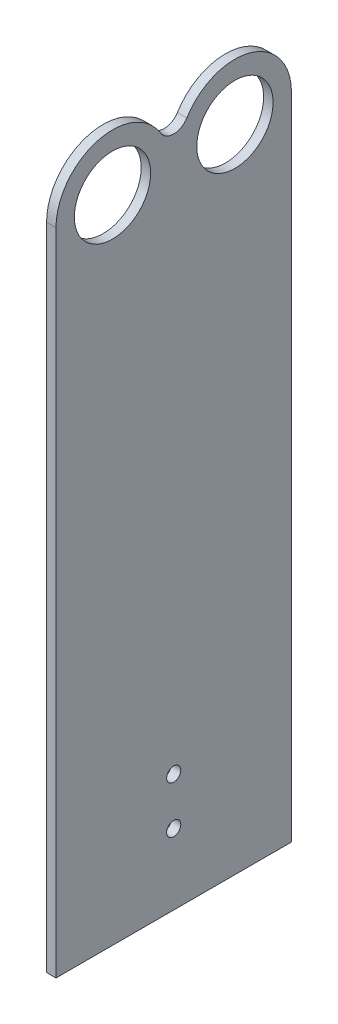
from build123d import *

# Parameters (mm, degrees)
SKETCH1_W               = 2
SKETCH1_H               = 150
BOSS_EXTRUDE1_DEPTH     = 50
SKETCH3_R               = 8.1
CUT_EXTRUDE2_DEPTH      = 50
SKETCH4_R               = 1.5
CUT_EXTRUDE3_DEPTH      = 1
CUT_EXTRUDE3_DEPTH_BACK = 3


with BuildPart() as part:
    # Sketch1 → Boss-Extrude1 (new body)
    with BuildSketch(Plane.XY):
        with Locations((1, -40)):
            Rectangle(SKETCH1_W, SKETCH1_H)
    extrude(amount=BOSS_EXTRUDE1_DEPTH)

    # Sketch3 → Cut-Extrude2 (cut)
    with BuildSketch(Plane(origin=(2, 0, 0), x_dir=(0, 0, -1), z_dir=(1, 0, 0))):
        with Locations((-12, 23)):
            Circle(SKETCH3_R)
        with Locations((-38, 23)):
            Circle(SKETCH3_R)
        with BuildLine():
            ThreePointArc((-50, 23), (-46.485281374, 31.485281374), (-38, 35))
            Line((-38, 35), (-50, 35))
            Line((-50, 35), (-50, 23))
        make_face()
        with BuildLine():
            ThreePointArc((-22.2198998, 29.289169108), (-17.8536301, 33.475448184), (-12, 35))
            Line((-12, 35), (-38, 35))
            ThreePointArc((-38, 35), (-32.1463699, 33.475448184), (-27.7801002, 29.289169108))
            ThreePointArc((-27.7801002, 29.289169108), (-25, 27.735662478), (-22.2198998, 29.289169108))
        make_face()
        with BuildLine():
            Line((0, 35), (-12, 35))
            ThreePointArc((-12, 35), (-3.514718626, 31.485281374), (0, 23))
            Line((0, 23), (0, 35))
        make_face()
    extrude(amount=-CUT_EXTRUDE2_DEPTH, mode=Mode.SUBTRACT)

    # Sketch4 → Cut-Extrude3 (cut, two sides)
    with BuildSketch(Plane.ZY) as cut_extrude3_sk:
        with Locations((25, -100)):
            Circle(SKETCH4_R)
        with Locations((25, -90)):
            Circle(SKETCH4_R)
    extrude(amount=CUT_EXTRUDE3_DEPTH, mode=Mode.SUBTRACT)
    extrude(cut_extrude3_sk.sketch, amount=-CUT_EXTRUDE3_DEPTH_BACK, mode=Mode.SUBTRACT)


solid = part.part
